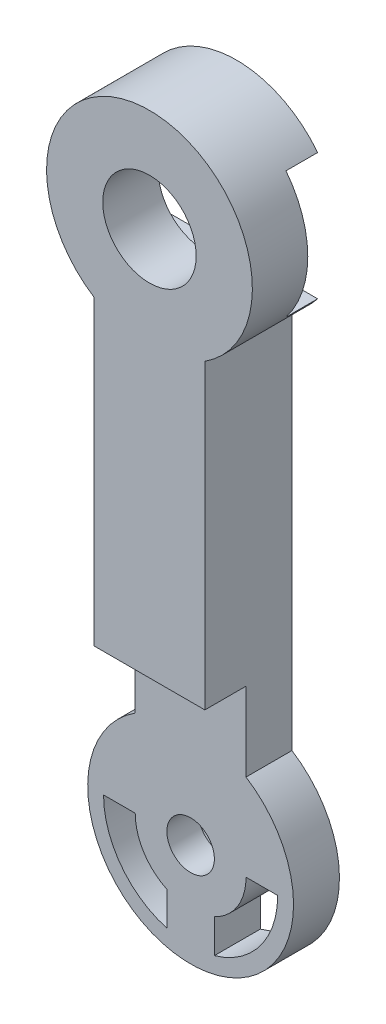
from build123d import *

# Parameters (mm, degrees)
BOSS_EXTRUDE1_DEPTH     = 3.7
SKETCH2_W               = 0.6
SKETCH2_H               = 16.95
CUT_EXTRUDE1_DEPTH      = 10
CUT_EXTRUDE1_DEPTH_BACK = 10
SKETCH3_R               = 2.95
SKETCH3_R_2             = 1.5
BOSS_EXTRUDE2_DEPTH     = 3.1
SKETCH4_R               = 2.5
CUT_EXTRUDE2_DEPTH      = 1.5
SKETCH5_R               = 1.5
BOSS_EXTRUDE3_DEPTH     = 0.4
SKETCH6_R               = 2.95
BOSS_EXTRUDE4_DEPTH     = 2.4
SKETCH7_W               = 22.104564564
SKETCH7_H               = 50.546801486
CUT_EXTRUDE3_DEPTH      = 0.6
SKETCH8_R               = 5.5
SKETCH8_R_2             = 3.5
BOSS_EXTRUDE5_DEPTH     = 5.5
CUT_EXTRUDE4_DEPTH      = 2


with BuildPart() as part:
    # Sketch1 → Boss-Extrude1 (new body)
    with BuildSketch(Plane.XY):
        with BuildLine():
            ThreePointArc((3.5, -5.477225575), (0, -6.5), (-3.5, -5.477225575))
            Line((-3.5, -5.477225575), (-3.5, -29.522774425))
            ThreePointArc((-3.5, -29.522774425), (0, -28.5), (3.5, -29.522774425))
            Line((3.5, -29.522774425), (3.5, -5.477225575))
        make_face()
        with BuildLine():
            ThreePointArc((-3.5, -4.242640687), (-4.974937186, -2.34520788), (-5.5, 0))
            ThreePointArc((-5.5, 0), (-4.387482194, 3.31662479), (-1.5, 5.291502622))
            ThreePointArc((-1.5, 5.291502622), (0, 5.5), (1.5, 5.291502622))
            ThreePointArc((1.5, 5.291502622), (4.387482194, 3.31662479), (5.5, 0))
            ThreePointArc((5.5, 0), (4.974937186, -2.34520788), (3.5, -4.242640687))
            Line((3.5, -4.242640687), (3.5, -5.477225575))
            ThreePointArc((3.5, -5.477225575), (5.700877125, -3.122498999), (6.5, 0))
            ThreePointArc((6.5, 0), (-3.122498999, 5.700877125), (-3.5, -5.477225575))
            Line((-3.5, -5.477225575), (-3.5, -4.242640687))
        make_face()
        with BuildLine():
            ThreePointArc((3.5, -4.242640687), (0, -5.5), (-3.5, -4.242640687))
            Line((-3.5, -4.242640687), (-3.5, -5.477225575))
            ThreePointArc((-3.5, -5.477225575), (0, -6.5), (3.5, -5.477225575))
            Line((3.5, -5.477225575), (3.5, -4.242640687))
        make_face()
        with BuildLine():
            ThreePointArc((3.5, 0), (0, -3.5), (-3.5, 0))
            Line((-3.5, 0), (-3.5, -4.242640687))
            ThreePointArc((-3.5, -4.242640687), (0, -5.5), (3.5, -4.242640687))
            Line((3.5, -4.242640687), (3.5, 0))
        make_face()
        with BuildLine():
            ThreePointArc((3.5, -29.522774425), (0, -28.5), (-3.5, -29.522774425))
            Line((-3.5, -29.522774425), (-3.5, -30.757359313))
            ThreePointArc((-3.5, -30.757359313), (0, -29.5), (3.5, -30.757359313))
            Line((3.5, -30.757359313), (3.5, -29.522774425))
        make_face()
        with BuildLine():
            Line((-3.5, -30.757359313), (-3.5, -29.522774425))
            ThreePointArc((-3.5, -29.522774425), (-3.122498999, -40.700877125), (6.5, -35))
            ThreePointArc((6.5, -35), (5.700877125, -31.877501001), (3.5, -29.522774425))
            Line((3.5, -29.522774425), (3.5, -30.757359313))
            ThreePointArc((3.5, -30.757359313), (4.974937186, -32.65479212), (5.5, -35))
            ThreePointArc((5.5, -35), (4.387482194, -38.31662479), (1.5, -40.291502622))
            ThreePointArc((1.5, -40.291502622), (0, -40.5), (-1.5, -40.291502622))
            ThreePointArc((-1.5, -40.291502622), (-4.387482194, -38.31662479), (-5.5, -35))
            ThreePointArc((-5.5, -35), (-4.974937186, -32.65479212), (-3.5, -30.757359313))
        make_face()
        with BuildLine():
            ThreePointArc((3.5, -30.757359313), (0, -29.5), (-3.5, -30.757359313))
            Line((-3.5, -30.757359313), (-3.5, -35))
            ThreePointArc((-3.5, -35), (0, -31.5), (3.5, -35))
            Line((3.5, -35), (3.5, -30.757359313))
        make_face()
        with BuildLine():
            Line((-3.5, -35), (-3.5, -30.757359313))
            ThreePointArc((-3.5, -30.757359313), (-4.974937186, -32.65479212), (-5.5, -35))
            Line((-5.5, -35), (-3.5, -35))
        make_face()
        with BuildLine():
            ThreePointArc((5.5, -35), (4.974937186, -32.65479212), (3.5, -30.757359313))
            Line((3.5, -30.757359313), (3.5, -35))
            Line((3.5, -35), (5.5, -35))
        make_face()
        with BuildLine():
            ThreePointArc((3.5, -35), (0, -31.5), (-3.5, -35))
            Line((-3.5, -35), (-2.95, -35))
            ThreePointArc((-2.95, -35), (0, -32.05), (2.95, -35))
            Line((2.95, -35), (3.5, -35))
        make_face()
        with BuildLine():
            Line((-2.95, -35), (-3.5, -35))
            ThreePointArc((-3.5, -35), (-2.958039892, -36.870828693), (-1.5, -38.16227766))
            ThreePointArc((-1.5, -38.16227766), (0, -38.5), (1.5, -38.16227766))
            ThreePointArc((1.5, -38.16227766), (2.958039892, -36.870828693), (3.5, -35))
            Line((3.5, -35), (2.95, -35))
            ThreePointArc((2.95, -35), (0, -37.95), (-2.95, -35))
        make_face()
        with BuildLine():
            Line((-1.5, 5.291502622), (-1.5, 3.16227766))
            ThreePointArc((-1.5, 3.16227766), (0, 3.5), (1.5, 3.16227766))
            Line((1.5, 3.16227766), (1.5, 5.291502622))
            ThreePointArc((1.5, 5.291502622), (0, 5.5), (-1.5, 5.291502622))
        make_face()
        with BuildLine():
            Line((-3.5, -4.242640687), (-3.5, 0))
            Line((-3.5, 0), (-5.5, 0))
            ThreePointArc((-5.5, 0), (-4.974937186, -2.34520788), (-3.5, -4.242640687))
        make_face()
        with BuildLine():
            Line((5.5, 0), (3.5, 0))
            Line((3.5, 0), (3.5, -4.242640687))
            ThreePointArc((3.5, -4.242640687), (4.974937186, -2.34520788), (5.5, 0))
        make_face()
        with BuildLine():
            ThreePointArc((-1.5, 3.16227766), (-2.958039892, 1.870828693), (-3.5, 0))
            Line((-3.5, 0), (-2.95, 0))
            ThreePointArc((-2.95, 0), (0, 2.95), (2.95, 0))
            Line((2.95, 0), (3.5, 0))
            ThreePointArc((3.5, 0), (2.958039892, 1.870828693), (1.5, 3.16227766))
            ThreePointArc((1.5, 3.16227766), (0, 3.5), (-1.5, 3.16227766))
        make_face()
        with BuildLine():
            Line((-2.95, 0), (-3.5, 0))
            ThreePointArc((-3.5, 0), (0, -3.5), (3.5, 0))
            Line((3.5, 0), (2.95, 0))
            ThreePointArc((2.95, 0), (0, -2.95), (-2.95, 0))
        make_face()
        with BuildLine():
            ThreePointArc((1.5, -38.16227766), (0, -38.5), (-1.5, -38.16227766))
            Line((-1.5, -38.16227766), (-1.5, -40.291502622))
            ThreePointArc((-1.5, -40.291502622), (0, -40.5), (1.5, -40.291502622))
            Line((1.5, -40.291502622), (1.5, -38.16227766))
        make_face()
    extrude(amount=BOSS_EXTRUDE1_DEPTH)

    # Sketch2 → Cut-Extrude1 (cut, two sides)
    with BuildSketch(Plane(origin=(0, 0, 0), x_dir=(0, 0, -1), z_dir=(1, 0, 0))) as cut_extrude1_sk:
        with Locations((-3.4, -33.025)):
            Rectangle(SKETCH2_W, SKETCH2_H)
    extrude(amount=CUT_EXTRUDE1_DEPTH, mode=Mode.SUBTRACT)
    extrude(cut_extrude1_sk.sketch, amount=-CUT_EXTRUDE1_DEPTH_BACK, mode=Mode.SUBTRACT)

    # Sketch3 → Boss-Extrude2 (add)
    with BuildSketch(Plane(origin=(0, 0, 0), x_dir=(-1, 0, 0), z_dir=(0, 0, -1))):
        with Locations((0, -35)):
            Circle(SKETCH3_R)
        with Locations((0, -35)):
            Circle(SKETCH3_R_2, mode=Mode.SUBTRACT)
    extrude(amount=-BOSS_EXTRUDE2_DEPTH)

    # Sketch4 → Cut-Extrude2 (cut)
    with BuildSketch(Plane(origin=(0, 0, 0), x_dir=(-1, 0, 0), z_dir=(0, 0, -1))):
        with Locations((0, -35)):
            Circle(SKETCH4_R)
    extrude(amount=-CUT_EXTRUDE2_DEPTH, mode=Mode.SUBTRACT)

    # Sketch5 → Boss-Extrude3 (add)
    with BuildSketch(Plane.XY.offset(3.1)):
        with BuildLine():
            Line((3.5, -24.55), (-3.5, -24.55))
            Line((-3.5, -24.55), (-3.5, -29.522774425))
            ThreePointArc((-3.5, -29.522774425), (0, -41.5), (3.5, -29.522774425))
            Line((3.5, -29.522774425), (3.5, -24.55))
        make_face()
        with BuildLine():
            Line((-5.5, -35), (-3.5, -35))
            ThreePointArc((-3.5, -35), (-2.958039892, -36.870828693), (-1.5, -38.16227766))
            Line((-1.5, -38.16227766), (-1.5, -40.291502622))
            ThreePointArc((-1.5, -40.291502622), (-4.387482194, -38.31662479), (-5.5, -35))
        make_face(mode=Mode.SUBTRACT)
        with BuildLine():
            ThreePointArc((1.5, -38.16227766), (2.958039892, -36.870828693), (3.5, -35))
            Line((3.5, -35), (5.5, -35))
            ThreePointArc((5.5, -35), (4.387482194, -38.31662479), (1.5, -40.291502622))
            Line((1.5, -40.291502622), (1.5, -38.16227766))
        make_face(mode=Mode.SUBTRACT)
        with Locations(Location((0, -35, 0), (0, 0, 180))):
            Circle(SKETCH5_R, mode=Mode.SUBTRACT)
    extrude(amount=BOSS_EXTRUDE3_DEPTH)

    # Sketch6 → Boss-Extrude4 (add)
    with BuildSketch(Plane.XY.offset(3.7)):
        with BuildLine():
            Line((-3.5, -5.477225575), (-3.5, -24.55))
            Line((-3.5, -24.55), (3.5, -24.55))
            Line((3.5, -24.55), (3.5, -5.477225575))
            ThreePointArc((3.5, -5.477225575), (0, 6.5), (-3.5, -5.477225575))
        make_face()
        Circle(SKETCH6_R, mode=Mode.SUBTRACT)
        with BuildLine():
            Line((-1.5, 5.291502622), (-1.5, 3.16227766))
            ThreePointArc((-1.5, 3.16227766), (-2.958039892, 1.870828693), (-3.5, 0))
            Line((-3.5, 0), (-5.5, 0))
            ThreePointArc((-5.5, 0), (-4.387482194, 3.31662479), (-1.5, 5.291502622))
        make_face(mode=Mode.SUBTRACT)
        with BuildLine():
            Line((1.5, 5.291502622), (1.5, 3.16227766))
            ThreePointArc((1.5, 3.16227766), (2.958039892, 1.870828693), (3.5, 0))
            Line((3.5, 0), (5.5, 0))
            ThreePointArc((5.5, 0), (4.387482194, 3.31662479), (1.5, 5.291502622))
        make_face(mode=Mode.SUBTRACT)
    extrude(amount=BOSS_EXTRUDE4_DEPTH)

    # Sketch7 → Cut-Extrude3 (cut)
    with BuildSketch(Plane.XY):
        with Locations((0.952758093, -17.453923436)):
            Rectangle(SKETCH7_W, SKETCH7_H)
    extrude(amount=CUT_EXTRUDE3_DEPTH, mode=Mode.SUBTRACT)

    # Sketch8 → Boss-Extrude5 (add)
    with BuildSketch(Plane.XY.offset(6.1)):
        Circle(SKETCH8_R)
        Circle(SKETCH8_R_2, mode=Mode.SUBTRACT)
    extrude(amount=-BOSS_EXTRUDE5_DEPTH)

    # Sketch9 → Cut-Extrude4 (cut)
    with BuildSketch(Plane(origin=(0, 0, 0.6), x_dir=(-1, 0, 0), z_dir=(0, 0, -1))):
        with BuildLine():
            Line((0, 4), (-5.123475383, 4))
            ThreePointArc((-5.123475383, 4), (-6.5, 0), (-5.123475383, -4))
            Line((-5.123475383, -4), (0, -4))
            Line((0, -4), (0, -2.95))
            ThreePointArc((0, -2.95), (-2.95, 0), (0, 2.95))
            Line((0, 2.95), (0, 4))
        make_face()
        with BuildLine():
            Line((5.123475383, 4), (0, 4))
            Line((0, 4), (0, 2.95))
            ThreePointArc((0, 2.95), (2.085965005, 2.085965005), (2.95, 0))
            ThreePointArc((2.95, 0), (2.085965005, -2.085965005), (0, -2.95))
            Line((0, -2.95), (0, -4))
            Line((0, -4), (5.123475383, -4))
            ThreePointArc((5.123475383, -4), (6.5, 0), (5.123475383, 4))
        make_face()
    extrude(amount=-CUT_EXTRUDE4_DEPTH, mode=Mode.SUBTRACT)


solid = part.part
